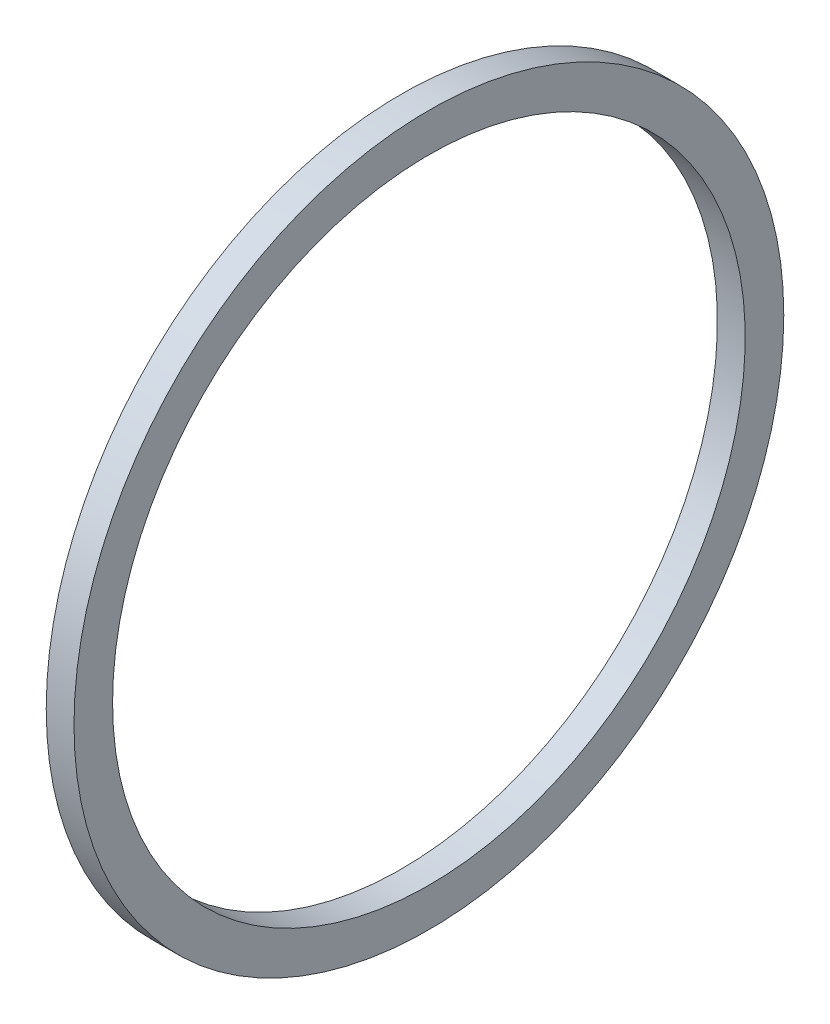
from build123d import *

# Parameters (mm, degrees)
SKETCH1_W = 9
SKETCH1_H = 12.5


with BuildPart() as part:
    # Sketch1 → Revolve1 (revolve)
    with BuildSketch(Plane.XY):
        with Locations((0, 108.75)):
            Rectangle(SKETCH1_W, SKETCH1_H)
    revolve(axis=Axis((0, 0, 0), (1, 0, 0)))


solid = part.part
